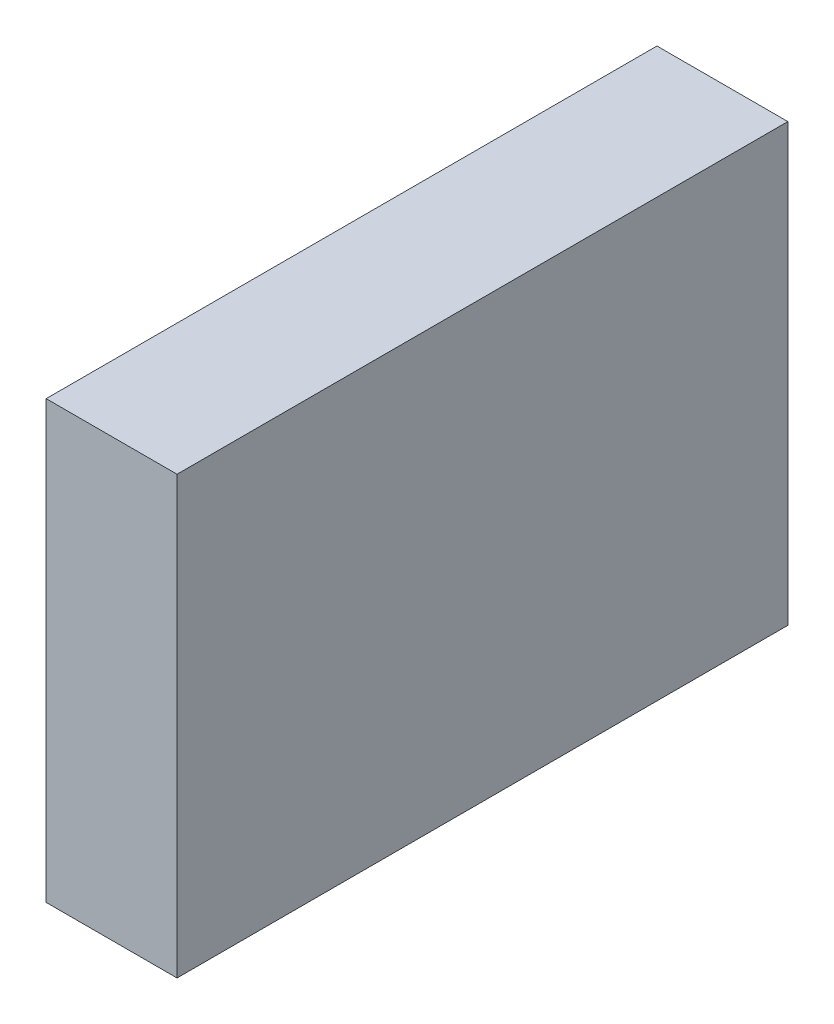
from build123d import *

# Parameters (mm, degrees)
SKETCH1_W           = 19.05
SKETCH1_H           = 88.9
BOSS_EXTRUDE1_DEPTH = 63.5


with BuildPart() as part:
    # Sketch1 → Boss-Extrude1 (new body)
    with BuildSketch(Plane(origin=(0, 0, 0), x_dir=(1, 0, 0), z_dir=(0, 1, 0))):
        Rectangle(SKETCH1_W, SKETCH1_H)
    extrude(amount=BOSS_EXTRUDE1_DEPTH)


solid = part.part
